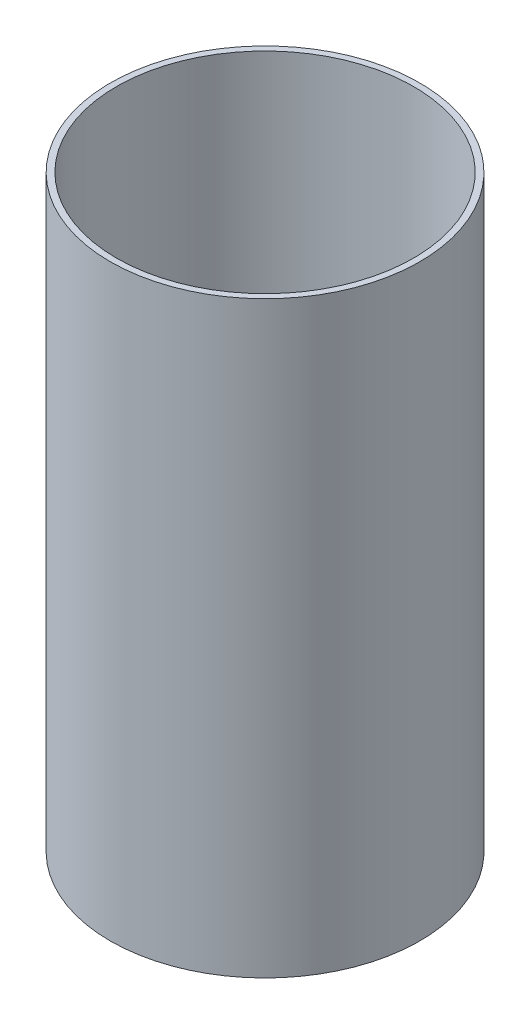
from build123d import *

# Parameters (mm, degrees)
SKETCH1_R           = 38.1
SKETCH1_R_2         = 36.576
BOSS_EXTRUDE1_DEPTH = 72.39


with BuildPart() as part:
    # Sketch1 → Boss-Extrude1 (new body, symmetric)
    with BuildSketch(Plane(origin=(0, 0, 0), x_dir=(1, 0, 0), z_dir=(0, 1, 0))):
        Circle(SKETCH1_R)
        Circle(SKETCH1_R_2, mode=Mode.SUBTRACT)
    extrude(amount=BOSS_EXTRUDE1_DEPTH, both=True)


solid = part.part
